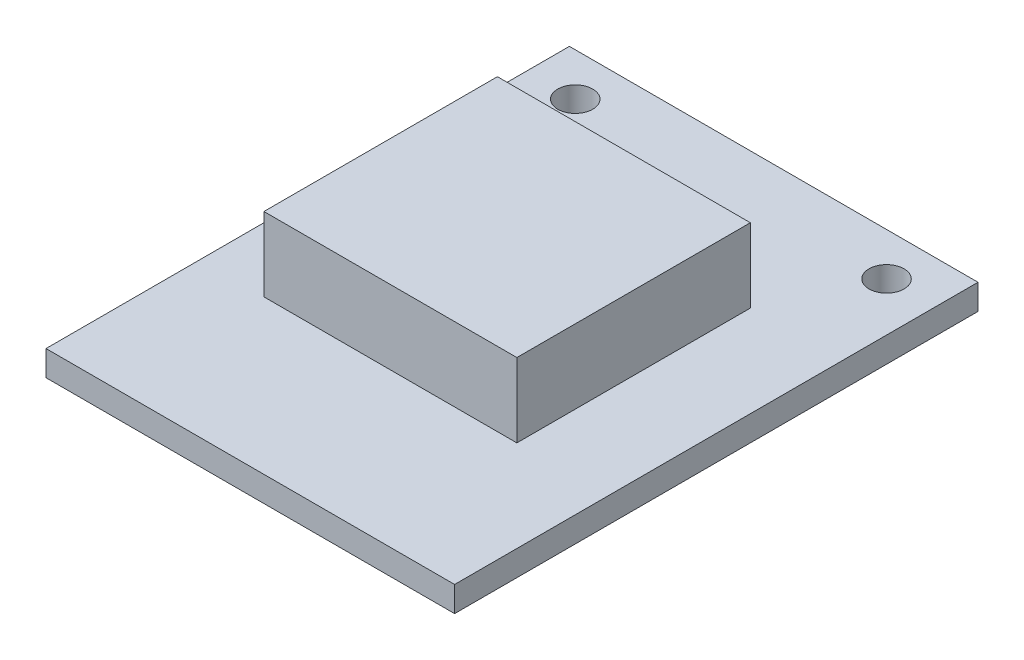
from build123d import *

# Parameters (mm, degrees)
SKETCH1_W           = 26.67
SKETCH1_H           = 34.163
SKETCH1_R           = 1.143
BOSS_EXTRUDE1_DEPTH = 1.651
SKETCH2_W           = 16.51
SKETCH2_H           = 15.24
BOSS_EXTRUDE2_DEPTH = 4.826


with BuildPart() as part:
    # Sketch1 → Boss-Extrude1 (new body)
    with BuildSketch(Plane(origin=(0, 0, 0), x_dir=(1, 0, 0), z_dir=(0, 1, 0))):
        with Locations((10.16, -14.2875)):
            Rectangle(SKETCH1_W, SKETCH1_H)
        Circle(SKETCH1_R, mode=Mode.SUBTRACT)
        with Locations((20.32, 0)):
            Circle(SKETCH1_R, mode=Mode.SUBTRACT)
    extrude(amount=BOSS_EXTRUDE1_DEPTH)

    # Sketch2 → Boss-Extrude2 (add)
    with BuildSketch(Plane(origin=(0, 1.651, 0), x_dir=(1, 0, 0), z_dir=(0, 1, 0))):
        with Locations((9.271, -13.716)):
            Rectangle(SKETCH2_W, SKETCH2_H)
    extrude(amount=BOSS_EXTRUDE2_DEPTH)


solid = part.part
